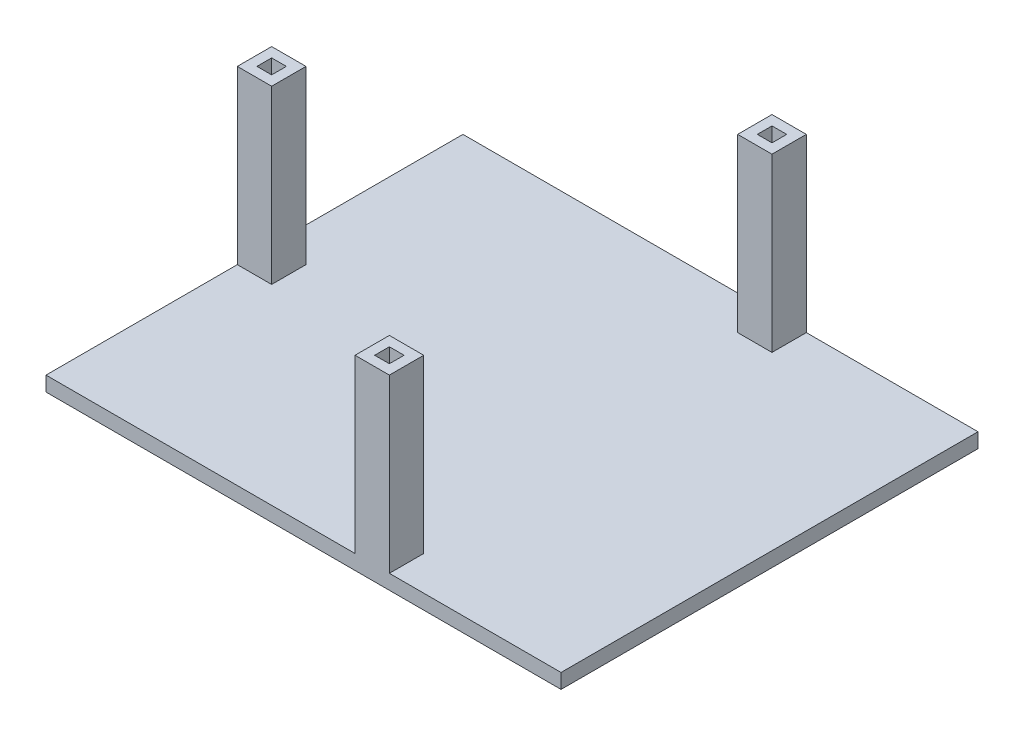
from build123d import *

# Parameters (mm, degrees)
SKETCH3_W           = 105
SKETCH3_H           = 85
BOSS_EXTRUDE3_DEPTH = 3
SKETCH5_W           = 7
SKETCH5_H           = 7
SKETCH5_W_2         = 3
SKETCH5_H_2         = 3
BOSS_EXTRUDE4_DEPTH = 35
SKETCH9_W           = 2.998895248
SKETCH9_H           = 2.995380601
BOSS_EXTRUDE5_DEPTH = 35
SKETCH11_W          = 7
SKETCH11_H          = 7
SKETCH11_W_2        = 3
SKETCH11_H_2        = 3
BOSS_EXTRUDE6_DEPTH = 35


with BuildPart() as part:
    # Sketch3 → Boss-Extrude3 (new body)
    with BuildSketch(Plane(origin=(0, 0, 0), x_dir=(1, 0, 0), z_dir=(0, 1, 0))):
        with Locations((-2.316884661, -22.898810939)):
            Rectangle(SKETCH3_W, SKETCH3_H)
    extrude(amount=BOSS_EXTRUDE3_DEPTH)

    # Sketch5 → Boss-Extrude4 (add)
    with BuildSketch(Plane(origin=(0, 3, 0), x_dir=(1, 0, 0), z_dir=(0, 1, 0))):
        with Locations((11.683115339, -61.898810939)):
            Rectangle(SKETCH5_W, SKETCH5_H)
        with Locations((11.683115339, -61.898810939)):
            Rectangle(SKETCH5_W_2, SKETCH5_H_2, mode=Mode.SUBTRACT)
    extrude(amount=BOSS_EXTRUDE4_DEPTH)

    # Sketch9 → Boss-Extrude5 (add)
    with BuildSketch(Plane(origin=(0, 3, 0), x_dir=(1, 0, 0), z_dir=(0, 1, 0))):
        Polygon((15.183115339, 12.601189061), (15.183115339, 19.601189061), (8.183115339, 19.601189061), (8.183115339, 17.600348451), (8.183115339, 12.601189061), align=None)
        with Locations((11.687877227, 16.102658151)):
            Rectangle(SKETCH9_W, SKETCH9_H, mode=Mode.SUBTRACT)
    extrude(amount=BOSS_EXTRUDE5_DEPTH)

    # Sketch11 → Boss-Extrude6 (add)
    with BuildSketch(Plane(origin=(0, 3, 0), x_dir=(1, 0, 0), z_dir=(0, 1, 0))):
        with Locations((-51.316884661, -22.898810939)):
            Rectangle(SKETCH11_W, SKETCH11_H)
        with Locations((-51.316884661, -22.898810939)):
            Rectangle(SKETCH11_W_2, SKETCH11_H_2, mode=Mode.SUBTRACT)
    extrude(amount=BOSS_EXTRUDE6_DEPTH)


solid = part.part
